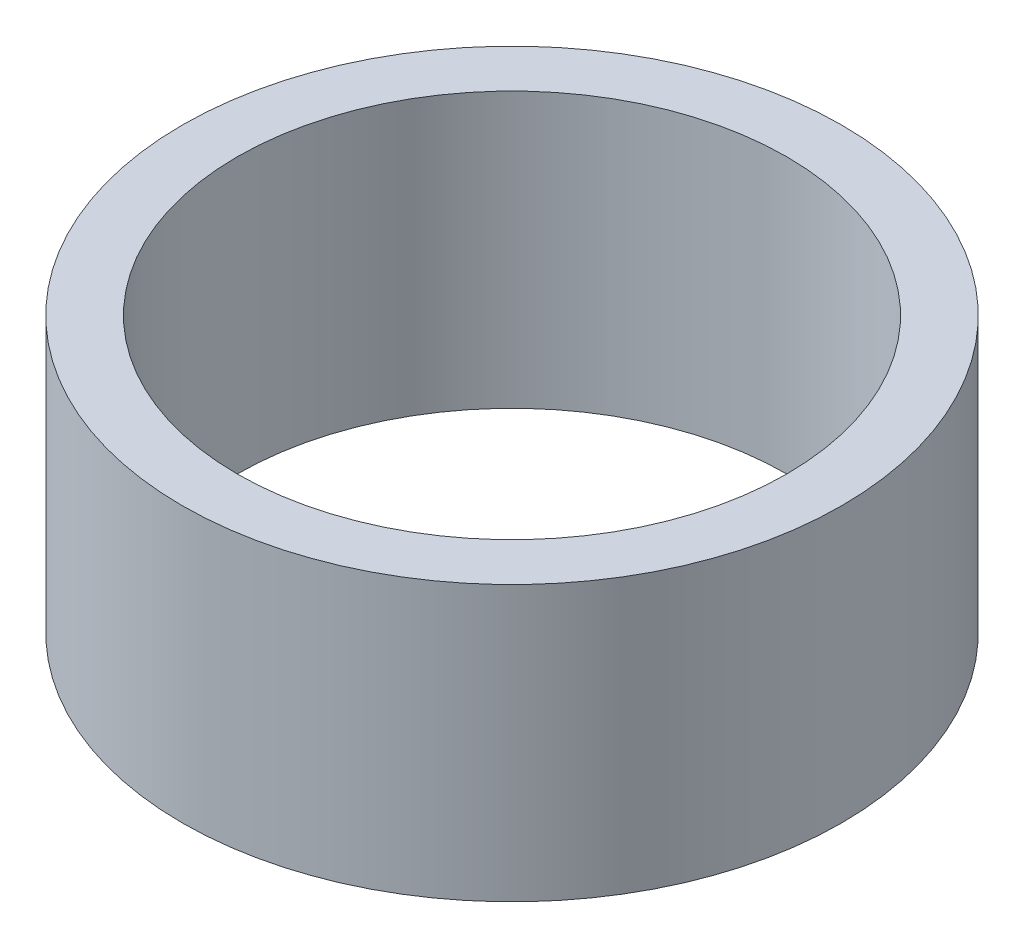
from build123d import *

# Parameters (mm, degrees)
SKETCH2_R           = 30
SKETCH2_R_2         = 25
BOSS_EXTRUDE1_DEPTH = 25


with BuildPart() as part:
    # Sketch2 → Boss-Extrude1 (new body)
    with BuildSketch(Plane(origin=(0, 0, 0), x_dir=(1, 0, 0), z_dir=(0, 1, 0))):
        Circle(SKETCH2_R)
        Circle(SKETCH2_R_2, mode=Mode.SUBTRACT)
    extrude(amount=BOSS_EXTRUDE1_DEPTH)


solid = part.part
